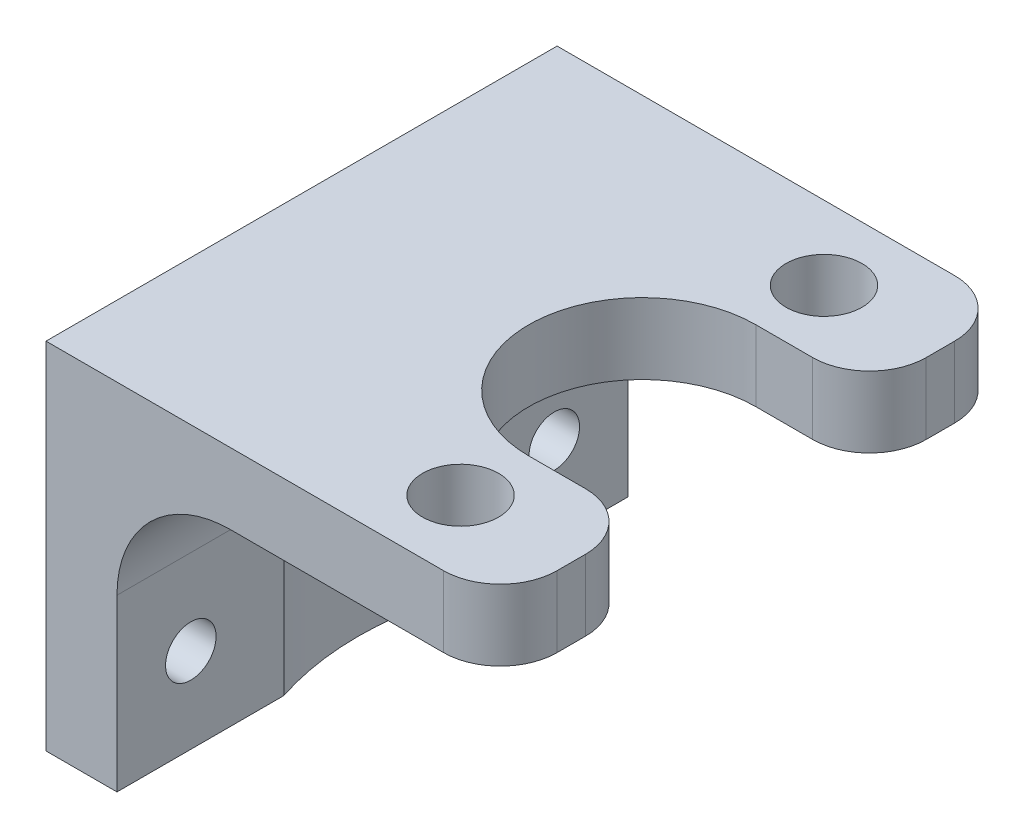
from build123d import *

# Parameters (mm, degrees)
SKETCH1_W             = 20.32
SKETCH1_H             = 22.86
BOSS_EXTRUDE1_DEPTH   = 3.175
FILLET1_R             = 2.54
FILLET2_R             = 2.54
CUT_EXTRUDE2_DEPTH    = 4.175
FILLET3_R             = 2.54
FILLET4_R             = 2.54
SKETCH4_W             = 3.175
SKETCH4_H             = 22.86
BOSS_EXTRUDE2_DEPTH   = 12.7
FILLET6_R             = 5.08
SKETCH5_R             = 12.7
CUT_EXTRUDE4_DEPTH    = 13.7
F_4_40_TAPPED_HOLE3_D = 2.2606
M3_CLEARANCE_HOLE1_D  = 3.4


with BuildPart() as part:
    # Sketch1 → Boss-Extrude1 (new body)
    with BuildSketch(Plane(origin=(0, 0, 0), x_dir=(1, 0, 0), z_dir=(0, 1, 0))):
        Rectangle(SKETCH1_W, SKETCH1_H)
    extrude(amount=BOSS_EXTRUDE1_DEPTH)

    # Fillet1
    fillet1_edges = [part.edges().sort_by_distance(p)[0] for p in [
        (10.16, 1.5875, -11.43),
    ]]
    fillet(fillet1_edges, radius=FILLET1_R)

    # Fillet2
    fillet2_edges = [part.edges().sort_by_distance(p)[0] for p in [
        (10.16, 1.5875, 11.43),
    ]]
    fillet(fillet2_edges, radius=FILLET2_R)

    # Sketch2 → Cut-Extrude2 (cut, through all)
    with BuildSketch(Plane.XZ):
        with BuildLine():
            Line((5.08, -5.08), (10.16, -5.08))
            Line((10.16, -5.08), (10.16, 5.08))
            Line((10.16, 5.08), (5.08, 5.08))
            ThreePointArc((5.08, 5.08), (0, 0), (5.08, -5.08))
        make_face()
    extrude(amount=-CUT_EXTRUDE2_DEPTH, mode=Mode.SUBTRACT)

    # Fillet3
    fillet3_edges = [part.edges().sort_by_distance(p)[0] for p in [
        (10.16, 1.5875, 5.08),
    ]]
    fillet(fillet3_edges, radius=FILLET3_R)

    # Fillet4
    fillet4_edges = [part.edges().sort_by_distance(p)[0] for p in [
        (10.16, 1.5875, -5.08),
    ]]
    fillet(fillet4_edges, radius=FILLET4_R)

    # Sketch4 → Boss-Extrude2 (add)
    with BuildSketch(Plane.XZ):
        with Locations((-8.5725, 0)):
            Rectangle(SKETCH4_W, SKETCH4_H)
    extrude(amount=BOSS_EXTRUDE2_DEPTH)

    # Fillet6
    fillet6_edges = [part.edges().sort_by_distance(p)[0] for p in [
        (-6.985, 0, 0),
    ]]
    fillet(fillet6_edges, radius=FILLET6_R)

    # Sketch5 → Cut-Extrude4 (cut, through all)
    with BuildSketch(Plane.XZ):
        with Locations((5.08, 0)):
            Circle(SKETCH5_R)
    extrude(amount=CUT_EXTRUDE4_DEPTH, mode=Mode.SUBTRACT)

    # #4-40 Tapped Hole3 (through all)
    with Locations(Plane(origin=(-6.985, 0, 0), x_dir=(0, 0, -1), z_dir=(1, 0, 0))):
        with Locations((-8.128, -8.89), (8.128, -8.89)):
            Hole(F_4_40_TAPPED_HOLE3_D / 2)

    # M3 Clearance Hole1 (through all)
    with Locations(Plane(origin=(0, 0, 0), x_dir=(-1, 0, 0), z_dir=(0, -1, 0))):
        with Locations((-5.08, -8.128), (-5.08, 8.128)):
            Hole(M3_CLEARANCE_HOLE1_D / 2)


solid = part.part
